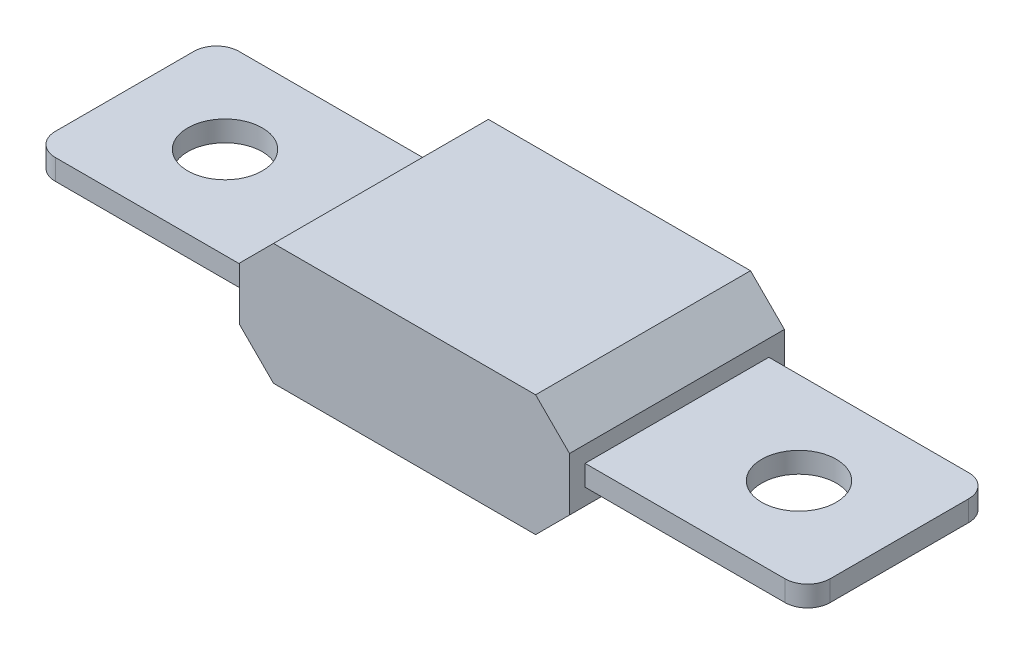
from build123d import *

# Parameters (mm, degrees)
SKETCH1_R                = 3.3
BOSS_EXTRUDE1_DEPTH      = 1.83
BOSS_EXTRUDE2_DEPTH      = 9.51
BOSS_EXTRUDE2_DEPTH_BACK = 9.51


with BuildPart() as part:
    # Sketch1 → Boss-Extrude1 (new body)
    with BuildSketch(Plane(origin=(0, 0, 0), x_dir=(1, 0, 0), z_dir=(0, 1, 0))):
        with BuildLine():
            Line((-32.29, 8.13), (32.29, 8.13))
            ThreePointArc((32.29, 8.13), (33.704213562, 7.544213562), (34.29, 6.13))
            Line((34.29, 6.13), (34.29, -6.13))
            ThreePointArc((34.29, -6.13), (33.704213562, -7.544213562), (32.29, -8.13))
            Line((32.29, -8.13), (-32.29, -8.13))
            ThreePointArc((-32.29, -8.13), (-33.704213562, -7.544213562), (-34.29, -6.13))
            Line((-34.29, -6.13), (-34.29, 6.13))
            ThreePointArc((-34.29, 6.13), (-33.704213562, 7.544213562), (-32.29, 8.13))
        make_face()
        with Locations((25.4, 0)):
            Circle(SKETCH1_R, mode=Mode.SUBTRACT)
        with Locations((-25.4, 0)):
            Circle(SKETCH1_R, mode=Mode.SUBTRACT)
    extrude(amount=BOSS_EXTRUDE1_DEPTH)

    # Sketch2 → Boss-Extrude2 (add, two sides)
    with BuildSketch(Plane.XY) as boss_extrude2_sk:
        Polygon((-14.6, 3.275), (-11.6, 6.275), (11.6, 6.275), (14.6, 3.275), (14.6, -1.445), (11.6, -4.445), (-11.6, -4.445), (-14.6, -1.445), align=None)
    extrude(amount=BOSS_EXTRUDE2_DEPTH)
    extrude(boss_extrude2_sk.sketch, amount=-BOSS_EXTRUDE2_DEPTH_BACK)


solid = part.part
